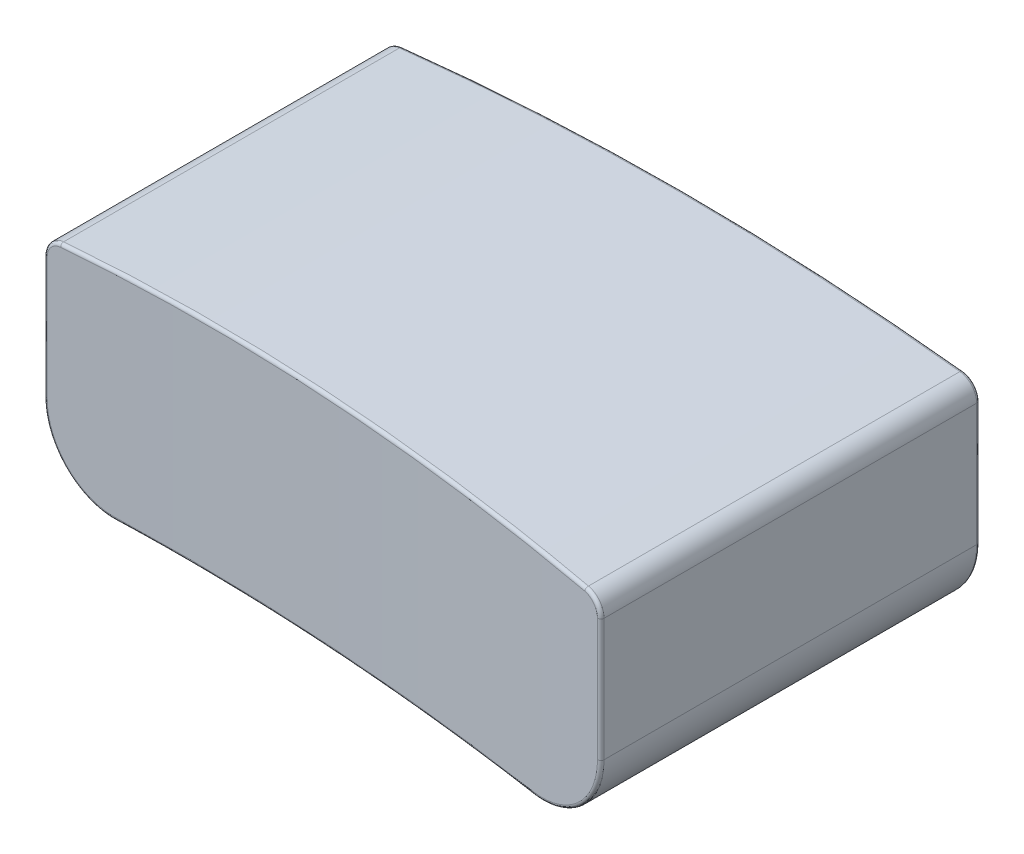
from build123d import *

# Parameters (mm, degrees)
SKETCH1_W               = 9.4
SKETCH1_H               = 3.7
BOSS_EXTRUDE1_DEPTH     = 3
CUT_EXTRUDE1_DEPTH      = 7.8
FILLET1_R               = 1.1
FILLET2_R               = 0.3
CUT_EXTRUDE2_START      = -2
SKETCH3_R               = 0.5
CUT_EXTRUDE2_DEPTH      = 13
FILLET4_R               = 0.02
CUT_EXTRUDE3_DEPTH      = 5
FILLET5_R               = 0.05
CUT_EXTRUDE4_REACH      = 17.868
CUT_EXTRUDE4_END_RADIUS = 50.4
CUT_EXTRUDE4_START      = -10
SKETCH5_R               = 0.4
FILLET6_R               = 0.05


with BuildPart() as part:
    # Sketch1 → Boss-Extrude1 (new, symmetric)
    with BuildSketch(Plane.XY):
        Rectangle(SKETCH1_W, SKETCH1_H)
    extrude(amount=BOSS_EXTRUDE1_DEPTH, both=True)

    # Sketch2 → Cut-Extrude1 (cut, symmetric)
    with BuildSketch(Plane.XY.offset(3)):
        with BuildLine():
            Line((-4.7, 1.55), (-7.120690005, 4.011417256))
            Line((-7.120690005, 4.011417256), (5.535860742, 3.886722174))
            Line((5.535860742, 3.886722174), (4.7, 1.55))
            ThreePointArc((4.7, 1.55), (0, 1.827084699), (-4.7, 1.55))
        make_face()
        with BuildLine():
            Line((4.7, -1.85), (0.350623614, -3.782025322))
            Line((0.350623614, -3.782025322), (-4.7, -1.85))
            ThreePointArc((-4.7, -1.85), (0, -1.628609864), (4.7, -1.85))
        make_face()
    extrude(amount=CUT_EXTRUDE1_DEPTH, both=True, mode=Mode.SUBTRACT)

    # Fillet1
    fillet1_edges = [part.edges().sort_by_distance(p)[0] for p in [
        (4.7, -1.85, 0),
        (-4.7, -1.85, 0),
    ]]
    fillet(fillet1_edges, radius=FILLET1_R)

    # Fillet2
    fillet2_edges = [part.edges().sort_by_distance(p)[0] for p in [
        (4.7, 1.55, 0),
        (-4.7, 1.55, 0),
    ]]
    fillet(fillet2_edges, radius=FILLET2_R)

    # Sketch3 → Cut-Extrude2 (cut)
    with BuildSketch(Plane.XY.offset(3).offset(CUT_EXTRUDE2_START)):
        with Locations((3.1, -0.6)):
            Circle(SKETCH3_R)
        with Locations((-3.1, -0.6)):
            Circle(SKETCH3_R)
    extrude(amount=-CUT_EXTRUDE2_DEPTH, mode=Mode.SUBTRACT)

    # Fillet4
    fillet4_edges = [part.edges().sort_by_distance(p)[0] for p in [
        (2.6, -0.6, -3),
        (-3.6, -0.6, -3),
    ]]
    fillet(fillet4_edges, radius=FILLET4_R)

    # Sketch4 → Cut-Extrude3 (cut, symmetric)
    with BuildSketch(Plane(origin=(0, 0, 0), x_dir=(1, 0, 0), z_dir=(0, 1, 0))):
        with BuildLine():
            Line((6.420677859, -4.774089961), (4.7, -3))
            ThreePointArc((4.7, -3), (0.004710726, -2.626198627), (-4.7, -2.4))
            Line((-4.7, -2.4), (-6.612719149, -3.913907535))
            Line((-6.612719149, -3.913907535), (6.420677859, -4.774089961))
        make_face()
    extrude(amount=CUT_EXTRUDE3_DEPTH, both=True, mode=Mode.SUBTRACT)

    # Fillet5
    fillet5_edges = [part.edges().sort_by_distance(p)[0] for p in [
        (4.7, 0.3134624, -3),
        (4.7, 0.3134624, 3),
        (0, -1.628609864, -3),
        (-4.349918456, -1.460327621, -3),
        (4.349918456, -1.460327621, -3),
        (0, 1.827084699, -3),
        (-4.7, 0.3134624, -3),
        (-4.623578634, 1.482534062, -3),
        (4.623578634, 1.482534062, -3),
        (2.6, -0.6, 1),
        (-4.623553452, 1.482562201, 2.402492735),
        (4.349071601, -1.461115946, 2.966925627),
        (-4.349757648, -1.460477444, 2.41174073),
        (4.623384041, 1.482751345, 2.992708087),
        (0.002641899, -1.628609931, 2.626066603),
        (-4.7, 0.3134624, 2.4),
        (0.004177998, 1.827084481, 2.626164624),
    ]]
    fillet(fillet5_edges, radius=FILLET5_R)

    # Cut-Extrude4: up to this cylinder (the profile starts inside it)
    cut_extrude4_end = Plane(origin=(0, -51.628609864, -1.5), z_dir=(0, 0, 1)) * Cylinder(CUT_EXTRUDE4_END_RADIUS, 137.536, mode=Mode.PRIVATE)
    # Sketch5 → Cut-Extrude4 (cut, up to the surface)
    with BuildSketch(Plane(origin=(0, 0, 0), x_dir=(1, 0, 0), z_dir=(0, 1, 0)).offset(CUT_EXTRUDE4_START), mode=Mode.PRIVATE) as cut_extrude4_sk1:
        with Locations(Location((-0.7, 1.5, 0), (0, 0, 90))):
            Circle(SKETCH5_R)
    cut_extrude4_tool1 = extrude(cut_extrude4_sk1.sketch, amount=CUT_EXTRUDE4_REACH, mode=Mode.PRIVATE) & cut_extrude4_end
    add(cut_extrude4_tool1.solids().sort_by_distance((-0.7, -10, -1.5))[0], mode=Mode.SUBTRACT)

    # Fillet6
    fillet6_edges = [part.edges().sort_by_distance(p)[0] for p in [
        (-0.700029875, -1.633510522, -1.100000001),
    ]]
    fillet(fillet6_edges, radius=FILLET6_R)


solid = part.part
